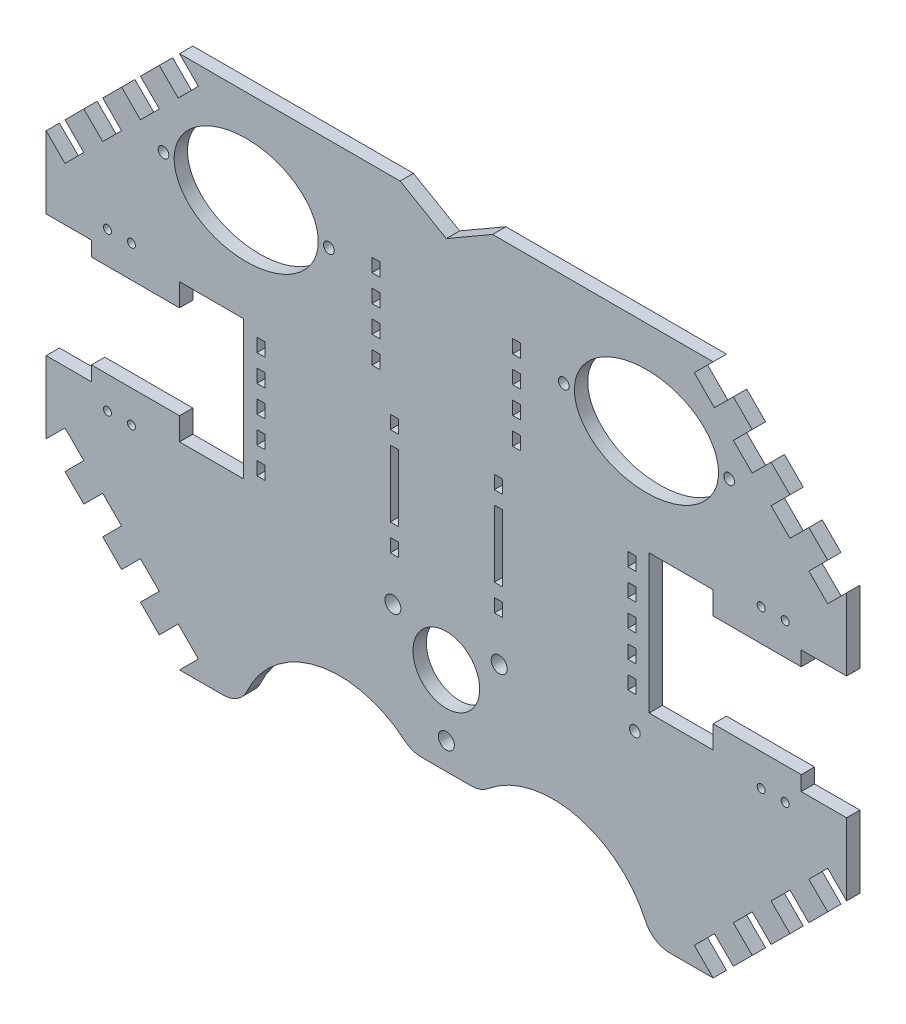
from build123d import *

# Parameters (mm, degrees)
ESQUISSE1_W                   = 3
ESQUISSE1_H                   = 5
ESQUISSE1_H_2                 = 25
BOSS_EXTRU_1_DEPTH            = 5
ENL_V_MAT_EXTRU_4_DEPTH       = 5
ENL_V_MAT_EXTRU_4_DEPTH_BACK  = 5
ESQUISSE2_R                   = 1.5
ESQUISSE2_R_2                 = 2
ESQUISSE2_RX                  = 27
ESQUISSE2_RY                  = 20
ENL_V_MAT_EXTRU_31_DEPTH      = 5
ENL_V_MAT_EXTRU_31_DEPTH_BACK = 5
ESQUISSE5_R                   = 12.5
ESQUISSE5_R_2                 = 3
CONG_7_R                      = 10
ENL_V_MAT_EXTRU_33_DEPTH      = 10
ENL_V_MAT_EXTRU_36_DEPTH      = 10
ESQUISSE20_W                  = 41.901166897
ESQUISSE20_H                  = 19.047591734
ENL_V_MAT_EXTRU_37_DEPTH      = 10
CONG_8_R                      = 10
ESQUISSE24_W                  = 3
ESQUISSE24_H                  = 5
ENL_V_MAT_EXTRU_40_DEPTH      = 10
ESQUISSE25_R                  = 2
ENL_V_MAT_EXTRU_41_DEPTH      = 10


with BuildPart() as part:
    # Esquisse1 → Boss.-Extru.1 (new body)
    with BuildSketch(Plane.XY):
        with BuildLine():
            Line((-150, -23), (-150, -100))
            Line((-150, -100), (-76.764248938, -100))
            ThreePointArc((-76.764248938, -100), (-40, -71.9), (-3.235751062, -100))
            Line((-3.235751062, -100), (3.235751062, -100))
            ThreePointArc((3.235751062, -100), (40, -71.9), (76.764248938, -100))
            Line((76.764248938, -100), (150, -100))
            Line((150, -100), (150, -23))
            Line((150, -23), (133, -23))
            Line((133, -23), (133, -17.5))
            Line((133, -17.5), (100, -17.5))
            Line((100, -17.5), (100, -26))
            Line((100, -26), (76, -26))
            Line((76, -26), (76, 26))
            Line((76, 26), (100, 26))
            Line((100, 26), (100, 17.5))
            Line((100, 17.5), (133, 17.5))
            Line((133, 17.5), (133, 23))
            Line((133, 23), (150, 23))
            Line((150, 23), (150, 100))
            Line((150, 100), (-36.423911741, 100))
            Line((-36.423911741, 100), (-37.766295471, 100))
            Line((-37.766295471, 100), (-150, 100))
            Line((-150, 100), (-150, 23))
            Line((-150, 23), (-133, 23))
            Line((-133, 23), (-133, 17.5))
            Line((-133, 17.5), (-100, 17.5))
            Line((-100, 17.5), (-100, 26))
            Line((-100, 26), (-76, 26))
            Line((-76, 26), (-76, -26))
            Line((-76, -26), (-100, -26))
            Line((-100, -26), (-100, -17.5))
            Line((-100, -17.5), (-133, -17.5))
            Line((-133, -17.5), (-133, -23))
            Line((-133, -23), (-150, -23))
        make_face()
        with Locations((-69.5, -20)):
            Rectangle(ESQUISSE1_W, ESQUISSE1_H, mode=Mode.SUBTRACT)
        with Locations((-69.5, -10)):
            Rectangle(ESQUISSE1_W, ESQUISSE1_H, mode=Mode.SUBTRACT)
        with Locations((-69.5, 0)):
            Rectangle(ESQUISSE1_W, ESQUISSE1_H, mode=Mode.SUBTRACT)
        with Locations((-19.5, -20)):
            Rectangle(ESQUISSE1_W, ESQUISSE1_H, mode=Mode.SUBTRACT)
        with Locations((-19.5, 0)):
            Rectangle(ESQUISSE1_W, ESQUISSE1_H_2, mode=Mode.SUBTRACT)
        with Locations((-69.5, 10)):
            Rectangle(ESQUISSE1_W, ESQUISSE1_H, mode=Mode.SUBTRACT)
        with Locations((-69.5, 20)):
            Rectangle(ESQUISSE1_W, ESQUISSE1_H, mode=Mode.SUBTRACT)
        with Locations((-19.5, 20)):
            Rectangle(ESQUISSE1_W, ESQUISSE1_H, mode=Mode.SUBTRACT)
        with Locations((19.5, -20)):
            Rectangle(ESQUISSE1_W, ESQUISSE1_H, mode=Mode.SUBTRACT)
        with Locations((19.5, 0)):
            Rectangle(ESQUISSE1_W, ESQUISSE1_H_2, mode=Mode.SUBTRACT)
        with Locations((69.5, -20)):
            Rectangle(ESQUISSE1_W, ESQUISSE1_H, mode=Mode.SUBTRACT)
        with Locations((69.5, -10)):
            Rectangle(ESQUISSE1_W, ESQUISSE1_H, mode=Mode.SUBTRACT)
        with Locations((69.5, 0)):
            Rectangle(ESQUISSE1_W, ESQUISSE1_H, mode=Mode.SUBTRACT)
        with Locations((19.5, 20)):
            Rectangle(ESQUISSE1_W, ESQUISSE1_H, mode=Mode.SUBTRACT)
        with Locations((69.5, 10)):
            Rectangle(ESQUISSE1_W, ESQUISSE1_H, mode=Mode.SUBTRACT)
        with Locations((69.5, 20)):
            Rectangle(ESQUISSE1_W, ESQUISSE1_H, mode=Mode.SUBTRACT)
    extrude(amount=BOSS_EXTRU_1_DEPTH)

    # Esquisse2 → Enlèv. mat.-Extru.4 (cut, two sides: drawn at the far end of the back side and taken through both)
    with BuildSketch(Plane.XY.offset(-ENL_V_MAT_EXTRU_4_DEPTH_BACK)):
        with Locations((-127, 29.5)):
            Circle(ESQUISSE2_R)
        with Locations((-118, 29.5)):
            Circle(ESQUISSE2_R)
        with Locations((-118, -29.5)):
            Circle(ESQUISSE2_R)
        with Locations((-127, -29.5)):
            Circle(ESQUISSE2_R)
        with Locations((118, 29.5)):
            Circle(ESQUISSE2_R)
        with Locations((127, 29.5)):
            Circle(ESQUISSE2_R)
        with Locations((118, -29.5)):
            Circle(ESQUISSE2_R)
        with Locations((127, -29.5)):
            Circle(ESQUISSE2_R)
        with Locations((-106, 65)):
            Circle(ESQUISSE2_R_2)
        with Locations((-44, 65)):
            Circle(ESQUISSE2_R_2)
        with Locations((44, 65)):
            Circle(ESQUISSE2_R_2)
        with Locations((106, 65)):
            Circle(ESQUISSE2_R_2)
        with Locations(Location((-75, 65), (0, 0, 0))):
            Ellipse(ESQUISSE2_RX, ESQUISSE2_RY)
        with Locations(Location((75, 65), (0, 0, 0))):
            Ellipse(ESQUISSE2_RX, ESQUISSE2_RY)
    extrude(amount=ENL_V_MAT_EXTRU_4_DEPTH + ENL_V_MAT_EXTRU_4_DEPTH_BACK, mode=Mode.SUBTRACT)

    # Esquisse5 → Enlèv. mat.-Extru.31 (cut, two sides: drawn at the far end of the back side and taken through both)
    with BuildSketch(Plane.XY.offset(5).offset(-ENL_V_MAT_EXTRU_31_DEPTH_BACK)):
        with Locations((0, -50)):
            Circle(ESQUISSE5_R)
        with Locations((0, -73)):
            Circle(ESQUISSE5_R_2)
        with Locations((-20.026632108, -38.68920841)):
            Circle(ESQUISSE5_R_2)
        with Locations((19.811626371, -38.316701642)):
            Circle(ESQUISSE5_R_2)
    extrude(amount=ENL_V_MAT_EXTRU_31_DEPTH + ENL_V_MAT_EXTRU_31_DEPTH_BACK, mode=Mode.SUBTRACT)

    # Congé7
    cong_7_edges = [part.edges().sort_by_distance(p)[0] for p in [
        (76.764248938, -100, 2.5),
        (-76.764248938, -100, 2.5),
    ]]
    fillet(cong_7_edges, radius=CONG_7_R)

    # Esquisse12 → Enlèv. mat.-Extru.33 (cut)
    with BuildSketch(Plane.XY.offset(5)):
        Polygon((17.32050808, 100), (-17.320508071, 100), (4e-09, 90), align=None)
    extrude(amount=-ENL_V_MAT_EXTRU_33_DEPTH, mode=Mode.SUBTRACT)

    # Esquisse19 → Enlèv. mat.-Extru.36 (cut)
    with BuildSketch(Plane(origin=(0, 0, 0), x_dir=(-1, 0, 0), z_dir=(0, 0, -1))):
        Polygon((-150, 100), (-150, 50), (-142.928932188, 42.928932188), (-135.857864376, 50), (-142.928932188, 57.071067812), (-135.857864376, 64.142135624), (-128.786796564, 57.071067812), (-121.715728753, 64.142135624), (-128.786796564, 71.213203436), (-121.715728753, 78.284271247), (-114.644660941, 71.213203436), (-107.573593129, 78.284271247), (-114.644660941, 85.355339059), (-107.573593129, 92.426406871), (-100.502525317, 85.355339059), (-92.928932188, 92.928932188), (-100, 100), align=None)
        Polygon((100, 100), (92.928932188, 92.928932188), (100.502525317, 85.355339059), (107.573593129, 92.426406871), (114.644660941, 85.355339059), (107.573593129, 78.284271247), (114.644660941, 71.213203436), (121.715728753, 78.284271247), (128.786796564, 71.213203436), (121.715728753, 64.142135624), (128.786796564, 57.071067812), (135.857864376, 64.142135624), (142.928932188, 57.071067812), (135.857864376, 50), (142.928932188, 42.928932188), (150, 50), (150, 100), align=None)
        Polygon((150, -100), (150, -50), (142.928932188, -42.928932188), (135.857864376, -50), (142.928932188, -57.071067812), (135.857864376, -64.142135624), (128.786796564, -57.071067812), (121.715728753, -64.142135624), (128.786796564, -71.213203436), (121.715728753, -78.284271247), (114.644660941, -71.213203436), (107.573593129, -78.284271247), (114.644660941, -85.355339059), (107.573593129, -92.426406871), (100.502525317, -85.355339059), (92.928932188, -92.928932188), (100, -100), align=None)
        Polygon((-100, -100), (-92.928932188, -92.928932188), (-100.502525317, -85.355339059), (-107.573593129, -92.426406871), (-114.644660941, -85.355339059), (-107.573593129, -78.284271247), (-114.644660941, -71.213203436), (-121.715728753, -78.284271247), (-128.786796564, -71.213203436), (-121.715728753, -64.142135624), (-128.786796564, -57.071067812), (-135.857864376, -64.142135624), (-142.928932188, -57.071067812), (-135.857864376, -50), (-142.928932188, -42.928932188), (-150, -50), (-150, -100), align=None)
    extrude(amount=-ENL_V_MAT_EXTRU_36_DEPTH, mode=Mode.SUBTRACT)

    # Esquisse20 → Enlèv. mat.-Extru.37 (cut)
    with BuildSketch(Plane(origin=(0, 0, 0), x_dir=(-1, 0, 0), z_dir=(0, 0, -1))):
        with Locations((2.516049145, -92.523795867)):
            Rectangle(ESQUISSE20_W, ESQUISSE20_H)
    extrude(amount=-ENL_V_MAT_EXTRU_37_DEPTH, mode=Mode.SUBTRACT)

    # Congé8
    cong_8_edges = [part.edges().sort_by_distance(p)[0] for p in [
        (-13.118593787, -83, 2.5),
        (13.118593787, -83, 2.5),
    ]]
    fillet(cong_8_edges, radius=CONG_8_R)

    # Esquisse24 → Enlèv. mat.-Extru.40 (cut)
    with BuildSketch(Plane(origin=(0, 0, 0), x_dir=(-1, 0, 0), z_dir=(0, 0, -1))):
        with Locations((26.35, 67.5)):
            Rectangle(ESQUISSE24_W, ESQUISSE24_H)
        with Locations((26.35, 57.5)):
            Rectangle(ESQUISSE24_W, ESQUISSE24_H)
        with Locations((26.35, 47.5)):
            Rectangle(ESQUISSE24_W, ESQUISSE24_H)
        with Locations((26.35, 37.5)):
            Rectangle(ESQUISSE24_W, ESQUISSE24_H)
        with Locations((-26.35, 37.5)):
            Rectangle(ESQUISSE24_W, ESQUISSE24_H)
        with Locations((-26.35, 47.5)):
            Rectangle(ESQUISSE24_W, ESQUISSE24_H)
        with Locations((-26.35, 57.5)):
            Rectangle(ESQUISSE24_W, ESQUISSE24_H)
        with Locations((-26.35, 67.5)):
            Rectangle(ESQUISSE24_W, ESQUISSE24_H)
    extrude(amount=-ENL_V_MAT_EXTRU_40_DEPTH, mode=Mode.SUBTRACT)

    # Esquisse25 → Enlèv. mat.-Extru.41 (cut)
    with BuildSketch(Plane(origin=(0, 0, 0), x_dir=(-1, 0, 0), z_dir=(0, 0, -1))):
        with Locations((-70.637680128, -34.553576473)):
            Circle(ESQUISSE25_R)
    extrude(amount=-ENL_V_MAT_EXTRU_41_DEPTH, mode=Mode.SUBTRACT)


solid = part.part
